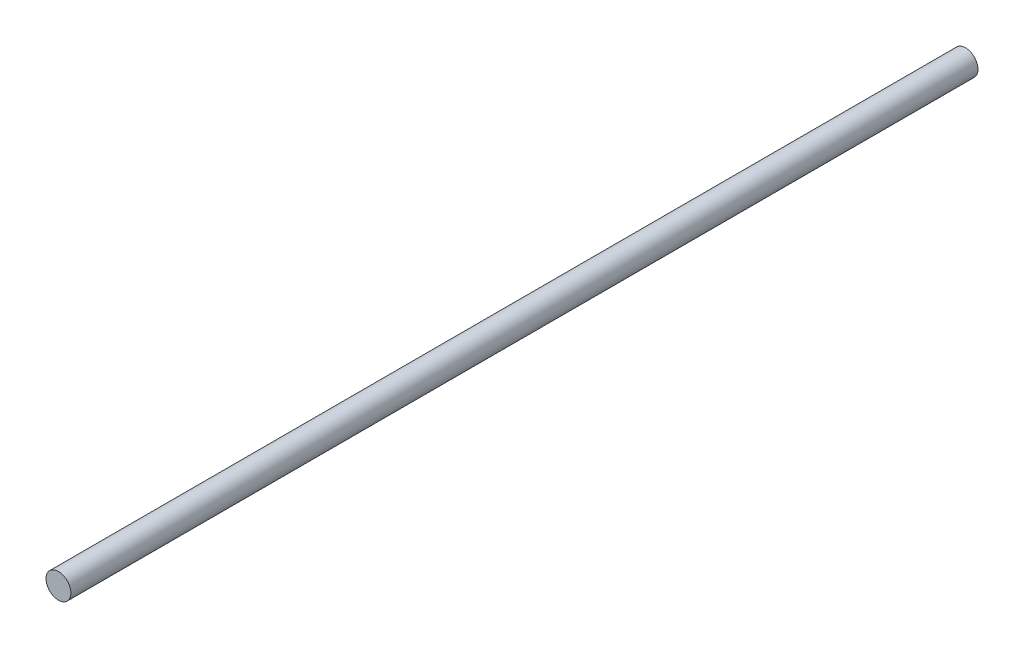
from build123d import *

# Parameters (mm, degrees)
SKETCH1_R           = 0.7
BOSS_EXTRUDE1_DEPTH = 51


with BuildPart() as part:
    # Sketch1 → Boss-Extrude1 (new body)
    with BuildSketch(Plane.XY):
        Circle(SKETCH1_R)
    extrude(amount=BOSS_EXTRUDE1_DEPTH)


solid = part.part
